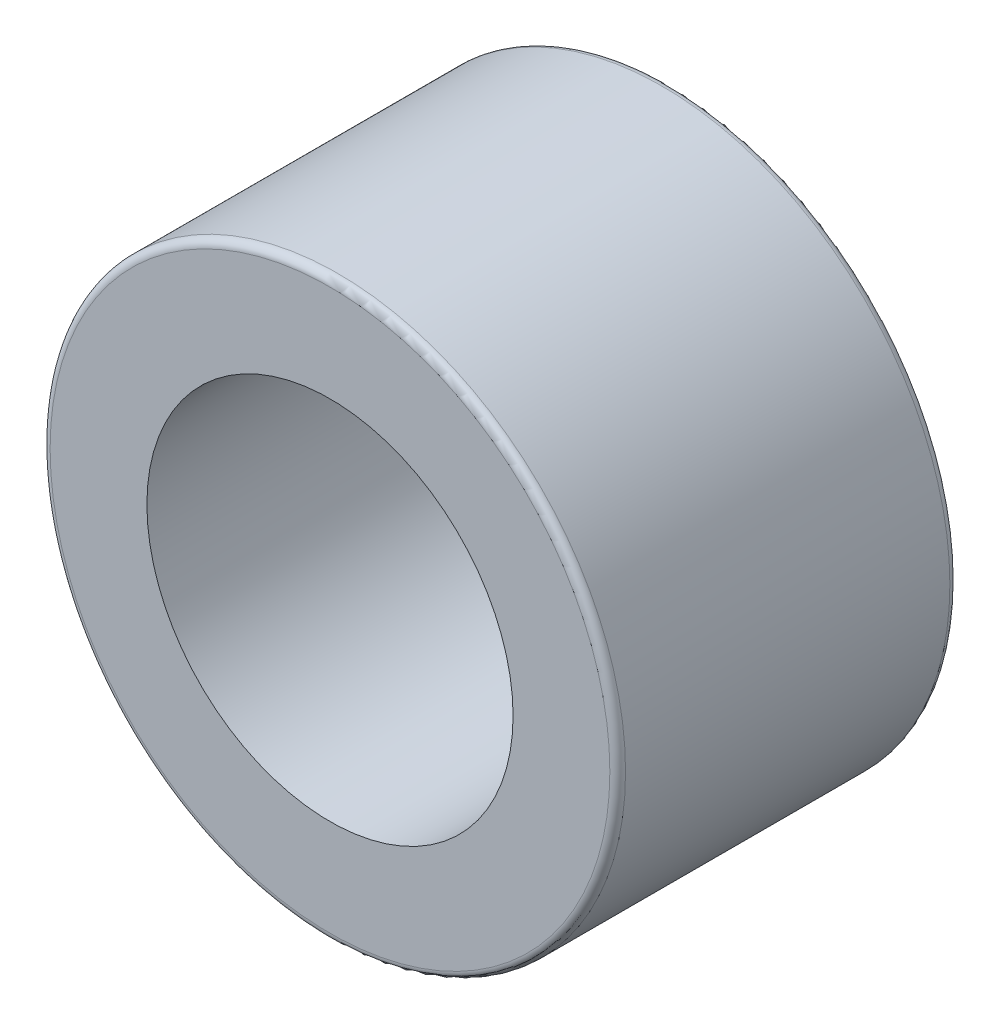
from build123d import *

# Parameters (mm, degrees)
SKETCH1_R           = 11
SKETCH1_R_2         = 7
BOSS_EXTRUDE1_DEPTH = 13
FILLET1_R           = 0.3


with BuildPart() as part:
    # Sketch1 → Boss-Extrude1 (new body)
    with BuildSketch(Plane.XY):
        Circle(SKETCH1_R)
        Circle(SKETCH1_R_2, mode=Mode.SUBTRACT)
    extrude(amount=BOSS_EXTRUDE1_DEPTH)

    # Fillet1
    fillet1_edges = [part.edges().sort_by_distance(p)[0] for p in [
        (-11, 0, 0),
        (-11, 0, 13),
    ]]
    fillet(fillet1_edges, radius=FILLET1_R)


solid = part.part
